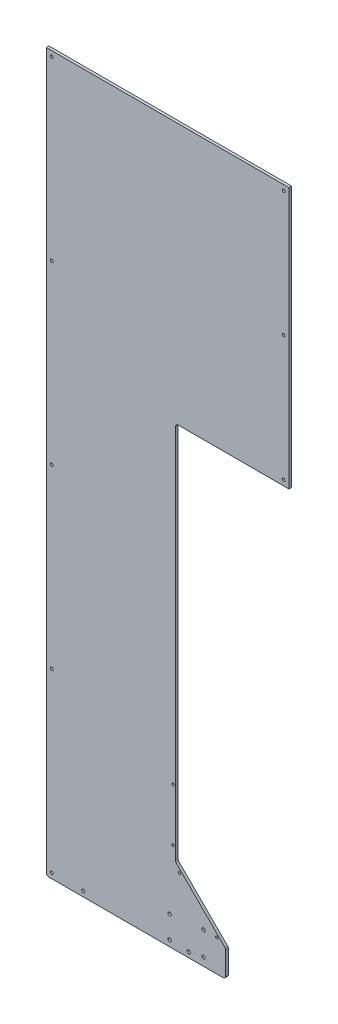
from build123d import *

# Parameters (mm, degrees)
SKETCH2_W                                       = 584.2
SKETCH2_H                                       = 1727.2
BOSS_EXTRUDE1_DEPTH                             = 6.35
CUT_EXTRUDE1_DEPTH                              = 7.35
H_0_266_DIAMETER_HOLE1_D                        = 6.7564
FILLET1_R                                       = 6.35
SKETCH7_R                                       = 3.96875
CUT_EXTRUDE2_DEPTH                              = 12.7
CSK_FOR_10_FLAT_HEAD_MACHINE_SCREW1_D           = 5.6134
CSK_FOR_10_FLAT_HEAD_MACHINE_SCREW1_CSINK_D     = 9.779
CSK_FOR_10_FLAT_HEAD_MACHINE_SCREW1_CSINK_ANGLE = 82
SKETCH15_R                                      = 3.937
CUT_EXTRUDE3_DEPTH                              = 7.35
F_5_16_0_3125_DIAMETER_HOLE1_D                  = 7.9375


with BuildPart() as part:
    # Sketch2 → Boss-Extrude1 (new body)
    with BuildSketch(Plane.XY):
        with Locations((292.1, 863.6)):
            Rectangle(SKETCH2_W, SKETCH2_H)
    extrude(amount=BOSS_EXTRUDE1_DEPTH)

    # Sketch3 → Cut-Extrude1 (cut, through all)
    with BuildSketch(Plane.XY.offset(6.35)):
        Polygon((584.2, 1098.55), (311.15, 1098.55), (311.15, 184.15), (431.8, 63.5), (431.8, 0), (584.2, 0), align=None)
    extrude(amount=-CUT_EXTRUDE1_DEPTH, mode=Mode.SUBTRACT)

    # H (0.266) Diameter Hole1 (through all)
    with Locations(Plane.XY.offset(6.35)):
        with Locations((12.7, 1714.5), (12.7, 1289.05), (12.7, 863.6), (12.7, 438.15), (12.7, 12.7), (571.5, 1111.25), (571.5, 1412.875), (571.5, 1714.5)):
            Hole(H_0_266_DIAMETER_HOLE1_D / 2)

    # Fillet1
    fillet1_edges = [part.edges().sort_by_distance(p)[0] for p in [
        (431.8, 0, 3.175),
        (431.8, 63.5, 3.175),
        (311.15, 184.15, 3.175),
        (311.15, 1098.55, 3.175),
        (0, 0, 3.175),
    ]]
    fillet(fillet1_edges, radius=FILLET1_R)

    # Sketch7 → Cut-Extrude2 (cut)
    with BuildSketch(Plane.XY.offset(6.35)):
        with Locations((88.9, 12.7)):
            Circle(SKETCH7_R)
        with Locations((342.9, 12.7)):
            Circle(SKETCH7_R)
    extrude(amount=-CUT_EXTRUDE2_DEPTH, mode=Mode.SUBTRACT)

    # CSK for #10 Flat Head Machine Screw1 (through all)
    with Locations(Plane(origin=(0, 0, 0), x_dir=(-1, 0, 0), z_dir=(0, 0, -1))):
        with Locations((-304.8, 342.9), (-304.8, 215.9), (-320.317182668, 166.002561211), (-410.119743879, 76.2)):
            CounterSinkHole(CSK_FOR_10_FLAT_HEAD_MACHINE_SCREW1_D / 2, CSK_FOR_10_FLAT_HEAD_MACHINE_SCREW1_CSINK_D / 2, counter_sink_angle=CSK_FOR_10_FLAT_HEAD_MACHINE_SCREW1_CSINK_ANGLE)

    # Sketch15 → Cut-Extrude3 (cut, through all)
    with BuildSketch(Plane.XY.offset(6.35)):
        with Locations((378.46762, 19.05)):
            Circle(SKETCH15_R)
        with Locations((378.46762, 76.2)):
            Circle(SKETCH15_R)
    extrude(amount=-CUT_EXTRUDE3_DEPTH, mode=Mode.SUBTRACT)

    # 5/16 (0.3125) Diameter Hole1 (through all)
    with Locations(Plane(origin=(0, 0, 0), x_dir=(-1, 0, 0), z_dir=(0, 0, -1))):
        with Locations((-296.8625, 68.2625), (-296.8625, 14.2875)):
            Hole(F_5_16_0_3125_DIAMETER_HOLE1_D / 2)


solid = part.part
